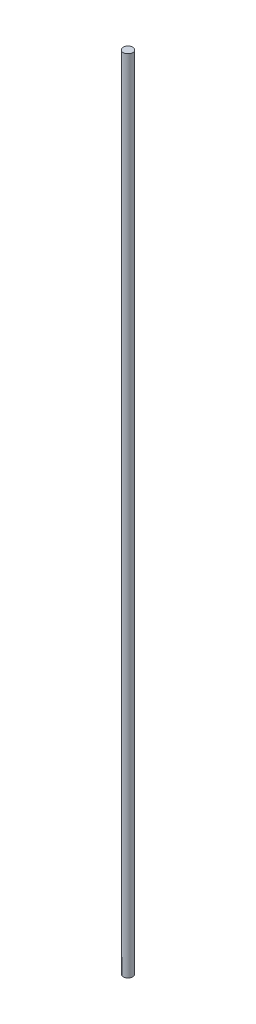
from build123d import *

# Parameters (mm, degrees)
ESBO_O1_R                = 3.97
RESSALTO_EXTRUS_O1_DEPTH = 335


with BuildPart() as part:
    # Esboço1 → Ressalto-extrusão1 (new body, symmetric)
    with BuildSketch(Plane(origin=(0, 0, 0), x_dir=(1, 0, 0), z_dir=(0, 1, 0))):
        Circle(ESBO_O1_R)
    extrude(amount=RESSALTO_EXTRUS_O1_DEPTH, both=True)


solid = part.part
